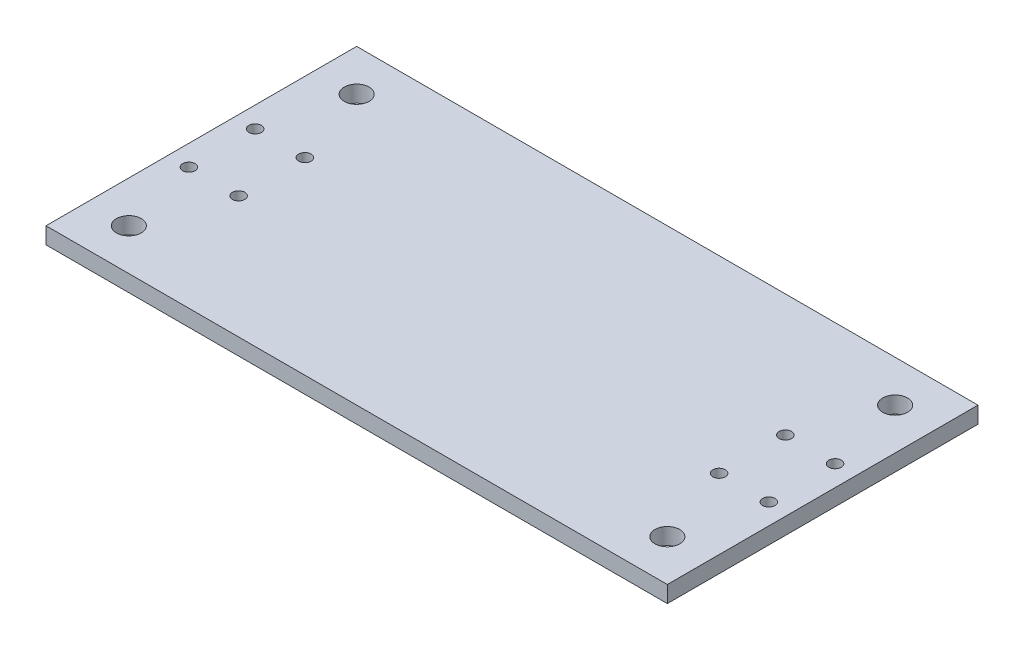
from build123d import *

# Parameters (mm, degrees)
SKETCH1_W           = 150
SKETCH1_H           = 75
SKETCH1_R           = 1.5
SKETCH1_R_2         = 3
BOSS_EXTRUDE1_DEPTH = 4


with BuildPart() as part:
    # Sketch1 → Boss-Extrude1 (new body)
    with BuildSketch(Plane(origin=(0, 0, 0), x_dir=(1, 0, 0), z_dir=(0, 1, 0))):
        Rectangle(SKETCH1_W, SKETCH1_H)
        with Locations((-70, 8)):
            Circle(SKETCH1_R, mode=Mode.SUBTRACT)
        with Locations((-70, -8)):
            Circle(SKETCH1_R, mode=Mode.SUBTRACT)
        with Locations((-58, -8)):
            Circle(SKETCH1_R, mode=Mode.SUBTRACT)
        with Locations((-58, 8)):
            Circle(SKETCH1_R, mode=Mode.SUBTRACT)
        with Locations((58, -8)):
            Circle(SKETCH1_R, mode=Mode.SUBTRACT)
        with Locations((70, -8)):
            Circle(SKETCH1_R, mode=Mode.SUBTRACT)
        with Locations((58, 8)):
            Circle(SKETCH1_R, mode=Mode.SUBTRACT)
        with Locations((70, 8)):
            Circle(SKETCH1_R, mode=Mode.SUBTRACT)
        with Locations((-65, 27.5)):
            Circle(SKETCH1_R_2, mode=Mode.SUBTRACT)
        with Locations((65, 27.5)):
            Circle(SKETCH1_R_2, mode=Mode.SUBTRACT)
        with Locations((-65, -27.5)):
            Circle(SKETCH1_R_2, mode=Mode.SUBTRACT)
        with Locations((65, -27.5)):
            Circle(SKETCH1_R_2, mode=Mode.SUBTRACT)
    extrude(amount=BOSS_EXTRUDE1_DEPTH)


solid = part.part
